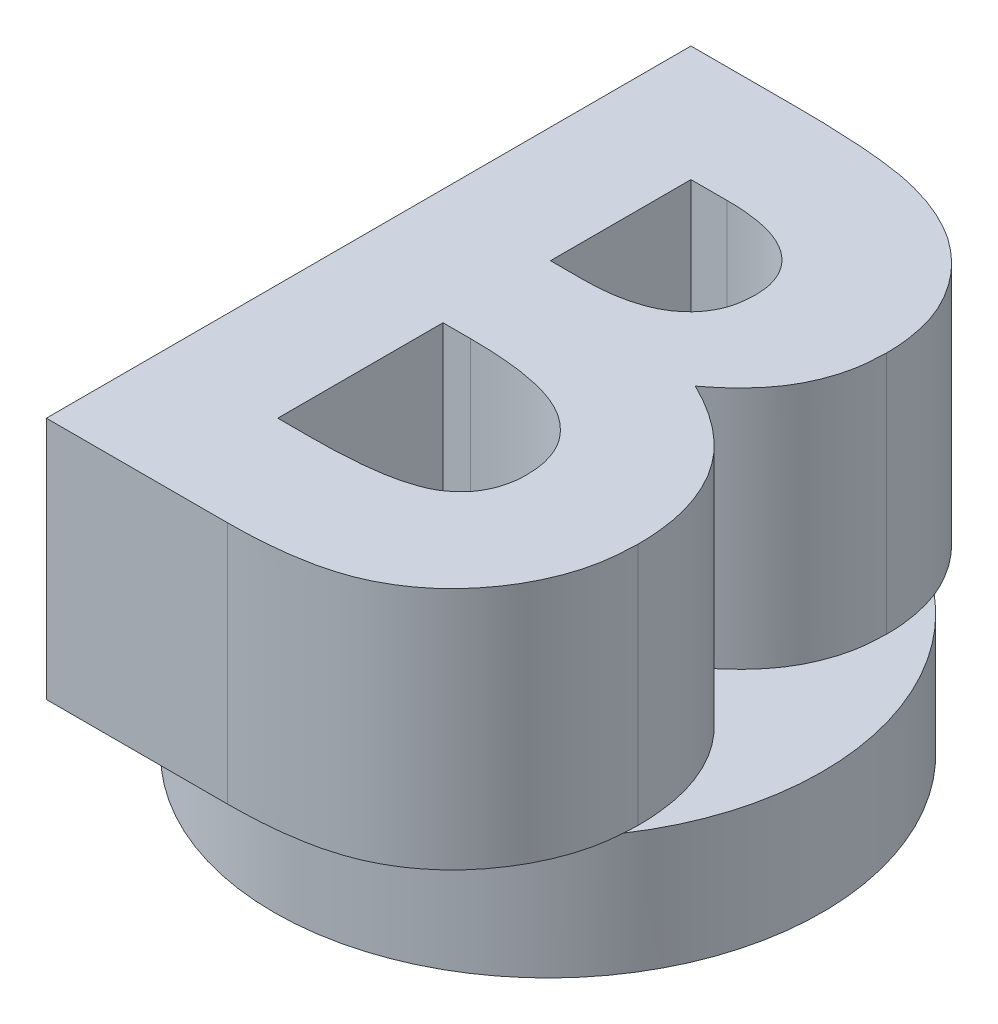
from build123d import *

# Parameters (mm, degrees)
SKETCH1_R           = 22.5
BOSS_EXTRUDE1_DEPTH = 10
BOSS_EXTRUDE2_DEPTH = 20
SKETCH3_R           = 16.5
CUT_EXTRUDE2_DEPTH  = 5


with BuildPart() as part:
    # Sketch1 → Boss-Extrude1 (new body)
    with BuildSketch(Plane(origin=(0, 0, 0), x_dir=(1, 0, 0), z_dir=(0, 1, 0))):
        with Locations(Location((0, 0, 0), (0, 0, 270))):
            Circle(SKETCH1_R)
    extrude(amount=BOSS_EXTRUDE1_DEPTH)

    # Sketch2 → Boss-Extrude2 (add)
    with BuildSketch(Plane(origin=(0, 10, 0), x_dir=(1, 0, 0), z_dir=(0, 1, 0))):
        with BuildLine():
            Line((-14.488149335, -26.70508671), (-14.488149335, 26.211579956))
            Line((-14.488149335, 26.211579956), (-6.007914293, 26.211579956))
            add(Edge.make_bspline(
                [(-6.007914293, 26.211579956), (-5.414244815, 26.211647709), (-4.265505631, 26.211778808), (-2.608174782, 26.15357879), (-1.071140386, 26.078290547), (0.340706119, 25.99406051), (1.629767793, 25.848915327), (2.794084408, 25.69594816), (3.835982274, 25.511479183), (4.480131109, 25.346004797), (4.783184799, 25.268153808)],
                knots=[0, 0, 0, 0, 1.311965854, 2.538629056, 3.664479157, 4.713267157, 5.663616078, 6.530575999, 7.308677837, 8, 8, 8, 8], degree=3))
            add(Edge.make_bspline(
                [(4.783184799, 25.268153808), (5.181125063, 25.158343602), (5.962011612, 24.942860725), (7.080490347, 24.507683744), (8.141523447, 24.023953675), (9.143815418, 23.472108139), (10.08121179, 22.845484813), (10.950150136, 22.139110625), (11.769371306, 21.381339407), (12.509786627, 20.551052288), (13.179000085, 19.673700144), (13.760426595, 18.749512867), (14.265611712, 17.792621882), (14.669892129, 16.790985354), (14.974509828, 15.749216088), (15.197305942, 14.671762602), (15.341707994, 13.555215567), (15.355352093, 12.795592125), (15.362278015, 12.409997424)],
                knots=[0, 0, 0, 0, 1.099996261, 2.158545794, 3.195537121, 4.207578794, 5.205712374, 6.197378256, 7.190519799, 8.17788031, 9.159561366, 10.129234751, 11.085776129, 12.040971148, 13.00380137, 13.975669004, 14.972423361, 16, 16, 16, 16], degree=3))
            add(Edge.make_bspline(
                [(15.362278015, 12.409997424), (15.344168787, 11.914609447), (15.308522997, 10.939499081), (15.080815259, 9.507238371), (14.653827774, 8.153546136), (14.095125035, 6.85347434), (13.335463983, 5.611872259), (12.370841368, 4.429330241), (11.216880916, 3.269436044), (10.331729546, 2.574157712), (9.871325825, 2.212514786)],
                knots=[0, 0, 0, 0, 0.986156485, 1.941127874, 2.875419072, 3.804401753, 4.751181392, 5.761612777, 6.835722519, 8, 8, 8, 8], degree=3))
            add(Edge.make_bspline(
                [(9.871325825, 2.212514786), (10.244414913, 2.022056041), (10.975939394, 1.648619138), (12.014489248, 1.034800345), (12.976073045, 0.381926211), (13.865002238, -0.296867174), (14.662630517, -1.030354847), (15.401893295, -1.77627224), (16.046319182, -2.577357317), (16.622584233, -3.40505788), (17.123464449, -4.271359131), (17.559675885, -5.174798081), (17.928128038, -6.118461074), (18.240142851, -7.09754563), (18.472843581, -8.115419342), (18.624569406, -9.172446243), (18.740740181, -10.265021335), (18.749777175, -11.009256203), (18.754372032, -11.387662164)],
                knots=[0, 0, 0, 0, 1.164658916, 2.283573913, 3.35186032, 4.395461096, 5.390182219, 6.362969632, 7.312859996, 8.245001507, 9.165155236, 10.092416118, 11.032087915, 11.979892451, 12.947605196, 13.931445124, 14.948243989, 16, 16, 16, 16], degree=3))
            add(Edge.make_bspline(
                [(18.754372032, -11.387662164), (18.724554483, -12.110395914), (18.665709669, -13.536708072), (18.235465105, -15.630861893), (17.48955774, -17.616309656), (16.487957959, -19.48516034), (15.25379432, -21.183313786), (13.834860053, -22.670881463), (12.245440572, -23.930074476), (10.779008994, -24.779932076), (9.510661162, -25.350265997), (8.46011235, -25.702882393), (7.331845194, -26.029545689), (6.105192549, -26.258935401), (4.802391955, -26.468898089), (3.410741024, -26.598533402), (1.932840727, -26.686384059), (0.917754918, -26.698726455), (0.394663165, -26.70508671)],
                knots=[0, 0, 0, 0, 1.284142165, 2.534249414, 3.780121997, 5.041676246, 6.291546858, 7.49970053, 8.684500223, 9.883330709, 10.50184324, 11.153274765, 11.851151195, 12.587658647, 13.369265475, 14.195992086, 15.070362669, 16, 16, 16, 16], degree=3))
            Line((0.394663165, -26.70508671), (-14.488149335, -26.70508671))
        make_face()
        with BuildLine():
            Line((-4.990286087, 16.713716709), (-4.990286087, 5.180597051))
            Line((-4.990286087, 5.180597051), (-2.467416162, 5.180597051))
            add(Edge.make_bspline(
                [(-2.467416162, 5.180597051), (-2.124535473, 5.1835871), (-1.462625052, 5.189359209), (-0.50656566, 5.263701973), (0.382415177, 5.390535346), (1.200945746, 5.567499807), (1.956650957, 5.79221887), (2.644703146, 6.062604299), (3.262077073, 6.392503912), (3.979322786, 6.883903943), (4.737503228, 7.607021089), (5.404920943, 8.65171363), (5.798025521, 9.853106078), (5.841806769, 10.700421057), (5.864414767, 11.137962168)],
                knots=[0, 0, 0, 0, 1.065314748, 2.056525647, 2.977365736, 3.853934255, 4.656397591, 5.425096493, 6.14721249, 6.826394842, 8.123232004, 9.372140726, 10.643011755, 12, 12, 12, 12], degree=3))
            add(Edge.make_bspline(
                [(5.864414767, 11.137962168), (5.84632423, 11.547792116), (5.811346902, 12.340181849), (5.415541135, 13.452767604), (4.800776528, 14.438746288), (4.074960502, 15.113568064), (3.391463676, 15.574451442), (2.80621175, 15.87792352), (2.163853815, 16.149588622), (1.451954509, 16.357310381), (0.674579167, 16.513177474), (-0.164496065, 16.627643188), (-1.06671888, 16.705553423), (-1.689886099, 16.710937246), (-2.011603529, 16.713716709)],
                knots=[0, 0, 0, 0, 1.347982417, 2.606269829, 3.849316587, 5.153353503, 5.842674298, 6.568177932, 7.326619318, 8.142485038, 9.012069166, 9.942760135, 10.937925643, 12, 12, 12, 12], degree=3))
            Line((-2.011603529, 16.713716709), (-4.990286087, 16.713716709))
        make_face(mode=Mode.SUBTRACT)
        with BuildLine():
            Line((-4.990286087, -3.638847394), (-4.990286087, -17.207223462))
            Line((-4.990286087, -17.207223462), (-2.255410286, -17.207223462))
            add(Edge.make_bspline(
                [(-2.255410286, -17.207223462), (-1.714721858, -17.204134529), (-0.675180886, -17.198195671), (0.813959715, -17.126440131), (2.167960807, -16.997113416), (3.383234797, -16.835659429), (4.461643108, -16.61691453), (5.399540462, -16.338808424), (6.209788904, -16.032843269), (6.887530146, -15.654939974), (7.441205914, -15.215154252), (7.940840245, -14.76568268), (8.348210945, -14.247174757), (8.670530245, -13.681888592), (8.94949703, -13.0838663), (9.117750095, -12.429755326), (9.245852073, -11.738941952), (9.252901868, -11.26112128), (9.256508784, -11.016651881)],
                knots=[0, 0, 0, 0, 1.753078804, 3.370512758, 4.83203934, 6.162291463, 7.344201807, 8.395507345, 9.331626367, 10.147333109, 10.898971645, 11.62040215, 12.321813352, 13.025280112, 13.727906689, 14.453419512, 15.208716525, 16, 16, 16, 16], degree=3))
            add(Edge.make_bspline(
                [(9.256508784, -11.016651881), (9.248554499, -10.737097279), (9.233061691, -10.192600118), (9.106531742, -9.396759406), (8.876585491, -8.653789298), (8.58695697, -7.944691045), (8.183923494, -7.294852835), (7.704931981, -6.681786232), (7.126187955, -6.126251562), (6.475356533, -5.594648013), (5.716226117, -5.129200305), (4.848440543, -4.725341973), (3.867285527, -4.388054368), (2.769721839, -4.119505755), (1.560561113, -3.891592259), (0.230977803, -3.755502742), (-1.207954859, -3.654286988), (-2.205734185, -3.644110867), (-2.721823214, -3.638847394)],
                knots=[0, 0, 0, 0, 0.845221588, 1.646264278, 2.427170338, 3.19324141, 3.95557735, 4.731569926, 5.540061037, 6.376114724, 7.268642756, 8.224665384, 9.265483498, 10.400594375, 11.639216012, 12.983232105, 14.439614077, 16, 16, 16, 16], degree=3))
            Line((-2.721823214, -3.638847394), (-4.990286087, -3.638847394))
        make_face(mode=Mode.SUBTRACT)
    extrude(amount=BOSS_EXTRUDE2_DEPTH)

    # Sketch3 → Cut-Extrude2 (cut)
    with BuildSketch(Plane.XZ):
        with BuildLine():
            ThreePointArc((-14.551420086, 2.778571429), (0, 11.5), (14.551420086, 2.778571429))
            Line((14.551420086, 2.778571429), (4.83856504, 20.948467447))
            ThreePointArc((4.83856504, 20.948467447), (0, 21.5), (-4.83856504, 20.948467447))
            Line((-4.83856504, 20.948467447), (-14.551420086, 2.778571429))
        make_face()
        with Locations((0, -5)):
            Circle(SKETCH3_R)
    extrude(amount=-CUT_EXTRUDE2_DEPTH, mode=Mode.SUBTRACT)


solid = part.part
